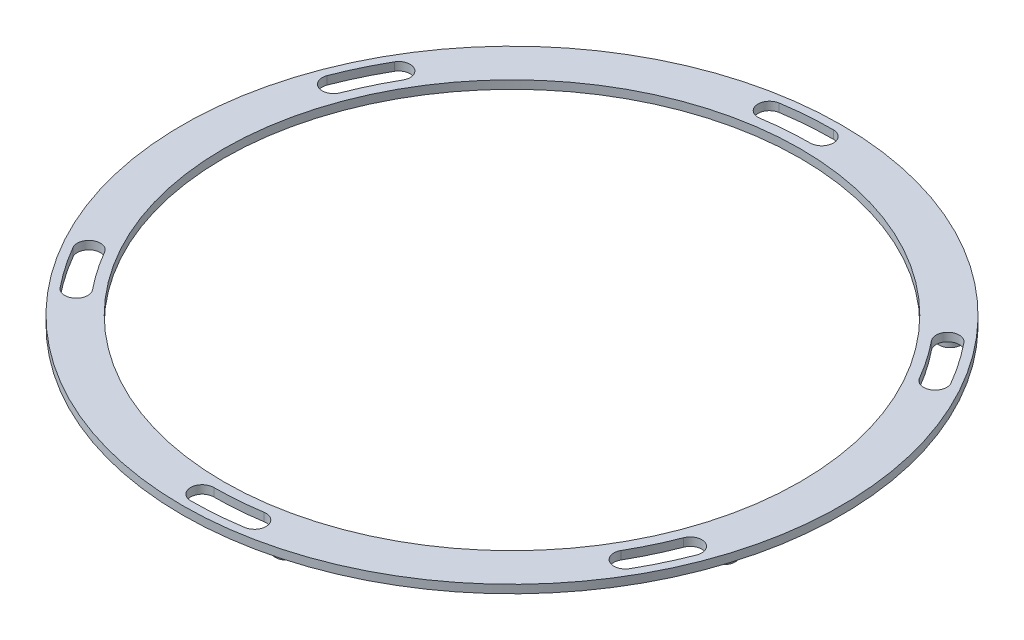
from build123d import *

# Parameters (mm, degrees)
SKETCH1_R           = 200
SKETCH1_R_2         = 175
BOSS_EXTRUDE1_DEPTH = 5
SKETCH2_R           = 2
CUT_EXTRUDE1_DEPTH  = 21
CIRPATTERN1_COUNT   = 6
SCALE1_SCALE        = 0.225
SKETCH3_R           = 1.5
BOSS_EXTRUDE2_DEPTH = 2.26


with BuildPart() as part:
    # Sketch1 → Boss-Extrude1 (new body)
    with BuildSketch(Plane(origin=(0, 0, 0), x_dir=(1, 0, 0), z_dir=(0, 1, 0))):
        Circle(SKETCH1_R)
        Circle(SKETCH1_R_2, mode=Mode.SUBTRACT)
    extrude(amount=BOSS_EXTRUDE1_DEPTH)

    # Sketch2 → Cut-Extrude1 (cut)
    with BuildSketch(Plane(origin=(0, 5, 0), x_dir=(1, 0, 0), z_dir=(0, 1, 0))):
        with Locations((-45.481316373, 182.41559654)):
            Circle(SKETCH2_R)
        with BuildLine():
            ThreePointArc((0, 195), (-15.299523667, 194.398880078), (-30.504720683, 192.599226416))
            ThreePointArc((-30.504720683, 192.599226416), (-36.323497812, 184.590366777), (-28.314638172, 178.771589648))
            ThreePointArc((-28.314638172, 178.771589648), (-14.201096327, 180.442037406), (0, 181))
            ThreePointArc((0, 181), (7, 188), (0, 195))
        make_face()
    cut_extrude1 = extrude(amount=-CUT_EXTRUDE1_DEPTH, mode=Mode.SUBTRACT)

    # CirPattern1: Cut-Extrude1 ×6 about axis
    cirpattern1_axis = Axis((0, 0, 0), (0, 1, 0))
    for i in range(1, CIRPATTERN1_COUNT):
        add(cut_extrude1.rotate(cirpattern1_axis, i * 360 / CIRPATTERN1_COUNT), mode=Mode.SUBTRACT)


with BuildPart() as part_1:
    # Scale1: scaled about (0, 2.5, 0)
    add(part.part.scale(SCALE1_SCALE).moved(Location((0, 1.9375, 0))))

    # Sketch3 → Boss-Extrude2 (add)
    with BuildSketch(Plane(origin=(0, 3.0625, 0), x_dir=(1, 0, 0), z_dir=(0, 1, 0))):
        with Locations((-10.233296184, 41.043509221)):
            Circle(SKETCH3_R)
        with Locations((30.428073554, 29.38404907)):
            Circle(SKETCH3_R)
        with Locations((40.661369738, -11.659460151)):
            Circle(SKETCH3_R)
        with Locations((10.233296184, -41.043509221)):
            Circle(SKETCH3_R)
        with Locations((-30.428073554, -29.38404907)):
            Circle(SKETCH3_R)
        with Locations((-40.661369738, 11.659460151)):
            Circle(SKETCH3_R)
    extrude(amount=-BOSS_EXTRUDE2_DEPTH)


solid = part_1.part
